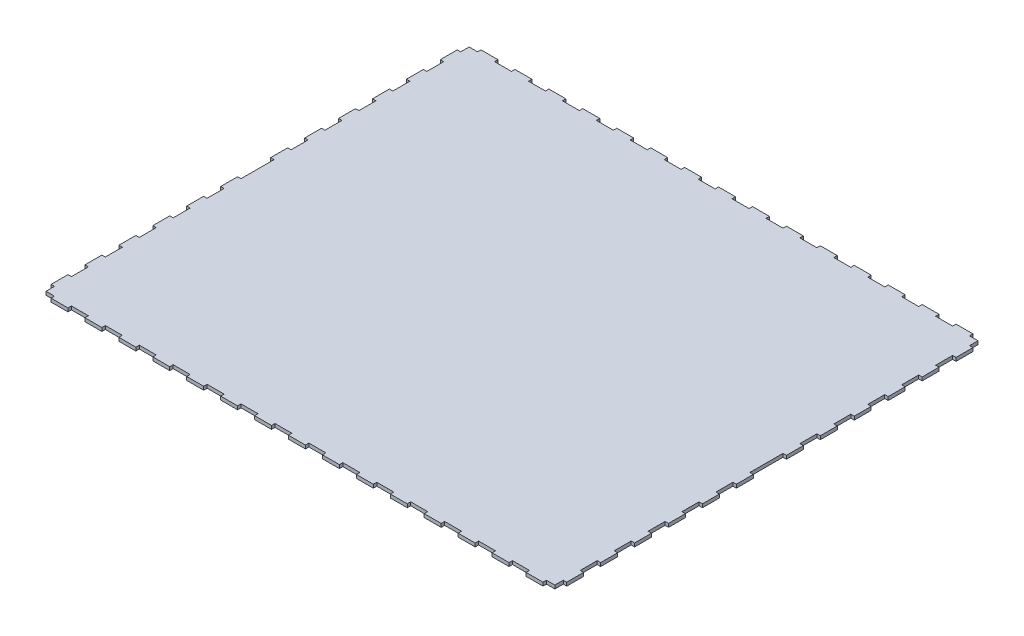
from build123d import *

# Parameters (mm, degrees)
BOSS_EXTRUDE1_DEPTH = 4


with BuildPart() as part:
    # Sketch1 → Boss-Extrude1 (new body)
    with BuildSketch(Plane(origin=(0, 0, 0), x_dir=(1, 0, 0), z_dir=(0, 1, 0))):
        Polygon((9.8625, 250), (-9.8625, 250), (-9.8625, 246), (-29.5875, 246), (-29.5875, 250), (-49.3125, 250), (-49.3125, 246), (-69.0375, 246), (-69.0375, 250), (-88.7625, 250), (-88.7625, 246), (-108.4875, 246), (-108.4875, 250), (-128.2125, 250), (-128.2125, 246), (-147.9375, 246), (-147.9375, 250), (-167.6625, 250), (-167.6625, 246), (-187.3875, 246), (-187.3875, 250), (-207.1125, 250), (-207.1125, 246), (-226.8375, 246), (-226.8375, 250), (-246.5625, 250), (-246.5625, 246), (-266.2875, 246), (-266.2875, 250), (-286.0125, 250), (-286.0125, 246), (-295.8125, 246), (-295.8125, 236.2), (-299.8125, 236.2), (-299.8125, 216.475), (-295.8125, 216.475), (-295.8125, 196.75), (-299.8125, 196.75), (-299.8125, 177.025), (-295.8125, 177.025), (-295.8125, 157.3), (-299.8125, 157.3), (-299.8125, 137.575), (-295.8125, 137.575), (-295.8125, 117.85), (-299.8125, 117.85), (-299.8125, 98.125), (-295.8125, 98.125), (-295.8125, 78.4), (-299.8125, 78.4), (-299.8125, 58.675), (-295.8125, 58.675), (-295.8125, 38.95), (-299.8125, 38.95), (-299.8125, 19.225), (-295.8125, 19.225), (-295.8125, -19.225), (-299.8125, -19.225), (-299.8125, -38.95), (-295.8125, -38.95), (-295.8125, -58.675), (-299.8125, -58.675), (-299.8125, -78.4), (-295.8125, -78.4), (-295.8125, -98.125), (-299.8125, -98.125), (-299.8125, -117.85), (-295.8125, -117.85), (-295.8125, -137.575), (-299.8125, -137.575), (-299.8125, -157.3), (-295.8125, -157.3), (-295.8125, -177.025), (-299.8125, -177.025), (-299.8125, -196.75), (-295.8125, -196.75), (-295.8125, -216.475), (-299.8125, -216.475), (-299.8125, -236.2), (-295.8125, -236.2), (-295.8125, -246), (-286.0125, -246), (-286.0125, -250), (-266.2875, -250), (-266.2875, -246), (-246.5625, -246), (-246.5625, -250), (-226.8375, -250), (-226.8375, -246), (-207.1125, -246), (-207.1125, -250), (-187.3875, -250), (-187.3875, -246), (-167.6625, -246), (-167.6625, -250), (-147.9375, -250), (-147.9375, -246), (-128.2125, -246), (-128.2125, -250), (-108.4875, -250), (-108.4875, -246), (-88.7625, -246), (-88.7625, -250), (-69.0375, -250), (-69.0375, -246), (-49.3125, -246), (-49.3125, -250), (-29.5875, -250), (-29.5875, -246), (-9.8625, -246), (-9.8625, -250), (9.8625, -250), (9.8625, -246), (29.5875, -246), (29.5875, -250), (49.3125, -250), (49.3125, -246), (69.0375, -246), (69.0375, -250), (88.7625, -250), (88.7625, -246), (108.4875, -246), (108.4875, -250), (128.2125, -250), (128.2125, -246), (147.9375, -246), (147.9375, -250), (167.6625, -250), (167.6625, -246), (187.3875, -246), (187.3875, -250), (207.1125, -250), (207.1125, -246), (226.8375, -246), (226.8375, -250), (246.5625, -250), (246.5625, -246), (266.2875, -246), (266.2875, -250), (286.0125, -250), (286.0125, -246), (295.8125, -246), (295.8125, -236.2), (299.8125, -236.2), (299.8125, -216.475), (295.8125, -216.475), (295.8125, -196.75), (299.8125, -196.75), (299.8125, -177.025), (295.8125, -177.025), (295.8125, -157.3), (299.8125, -157.3), (299.8125, -137.575), (295.8125, -137.575), (295.8125, -117.85), (299.8125, -117.85), (299.8125, -98.125), (295.8125, -98.125), (295.8125, -78.4), (299.8125, -78.4), (299.8125, -58.675), (295.8125, -58.675), (295.8125, -38.95), (299.8125, -38.95), (299.8125, -19.225), (295.8125, -19.225), (295.8125, 19.225), (299.8125, 19.225), (299.8125, 38.95), (295.8125, 38.95), (295.8125, 58.675), (299.8125, 58.675), (299.8125, 78.4), (295.8125, 78.4), (295.8125, 98.125), (299.8125, 98.125), (299.8125, 117.85), (295.8125, 117.85), (295.8125, 137.575), (299.8125, 137.575), (299.8125, 157.3), (295.8125, 157.3), (295.8125, 177.025), (299.8125, 177.025), (299.8125, 196.75), (295.8125, 196.75), (295.8125, 216.475), (299.8125, 216.475), (299.8125, 236.2), (295.8125, 236.2), (295.8125, 246), (286.0125, 246), (286.0125, 250), (266.2875, 250), (266.2875, 246), (246.5625, 246), (246.5625, 250), (226.8375, 250), (226.8375, 246), (207.1125, 246), (207.1125, 250), (187.3875, 250), (187.3875, 246), (167.6625, 246), (167.6625, 250), (147.9375, 250), (147.9375, 246), (128.2125, 246), (128.2125, 250), (108.4875, 250), (108.4875, 246), (88.7625, 246), (88.7625, 250), (69.0375, 250), (69.0375, 246), (49.3125, 246), (49.3125, 250), (29.5875, 250), (29.5875, 246), (9.8625, 246), align=None)
    extrude(amount=BOSS_EXTRUDE1_DEPTH)


solid = part.part
